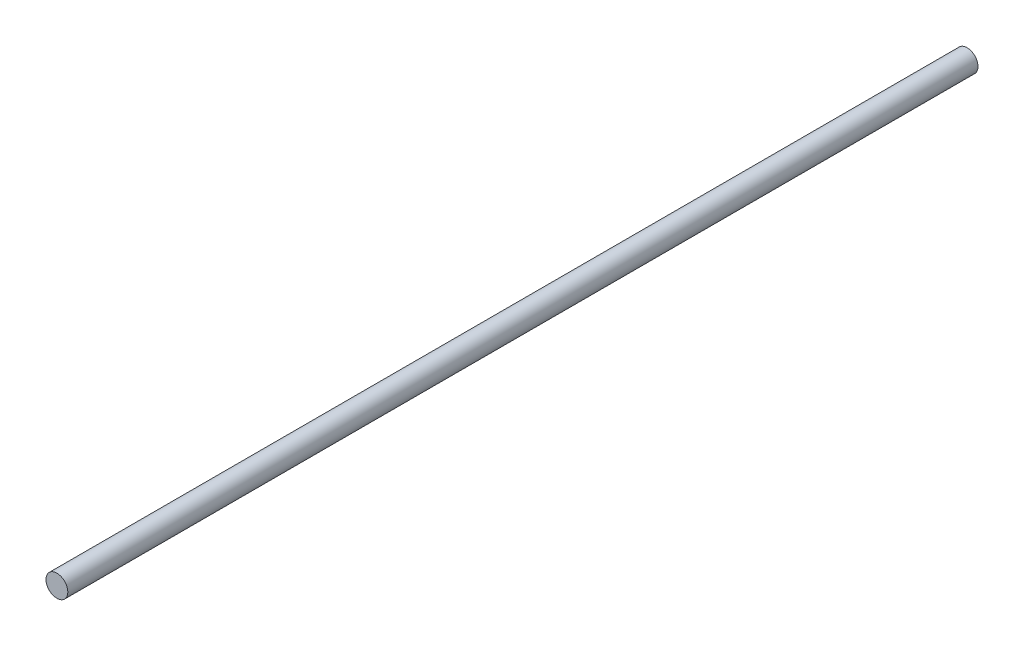
from build123d import *

# Parameters (mm, degrees)
SKETCH1_R           = 3
BOSS_EXTRUDE1_DEPTH = 250.35


with BuildPart() as part:
    # Sketch1 → Boss-Extrude1 (new body)
    with BuildSketch(Plane.XY):
        Circle(SKETCH1_R)
    extrude(amount=BOSS_EXTRUDE1_DEPTH)


solid = part.part
